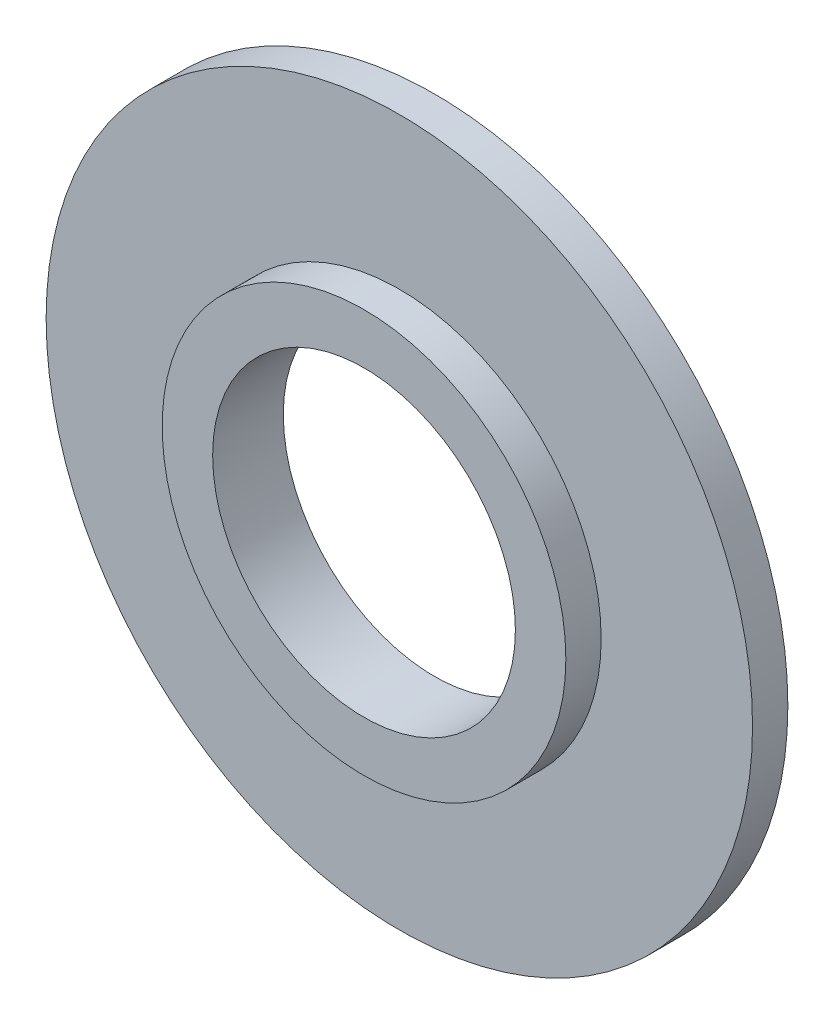
from build123d import *

# Parameters (mm, degrees)
SKETCH_1_R      = 4
SKETCH_1_R_2    = 3
EXTRUDE_1_DEPTH = 0.7
SKETCH_2_R      = 7
SKETCH_2_R_2    = 3
EXTRUDE_2_DEPTH = 0.7


with BuildPart() as part:
    # 草图1 → 凸台-拉伸1 (new body)
    with BuildSketch(Plane.XY):
        Circle(SKETCH_1_R)
        Circle(SKETCH_1_R_2, mode=Mode.SUBTRACT)
    extrude(amount=-EXTRUDE_1_DEPTH)

    # 草图2 → 凸台-拉伸2 (add)
    with BuildSketch(Plane(origin=(0, 0, -0.7), x_dir=(-1, 0, 0), z_dir=(0, 0, -1))):
        Circle(SKETCH_2_R)
        with Locations(Location((0, 0, 0), (0, 0, 180))):
            Circle(SKETCH_2_R_2, mode=Mode.SUBTRACT)
    extrude(amount=EXTRUDE_2_DEPTH)


solid = part.part
